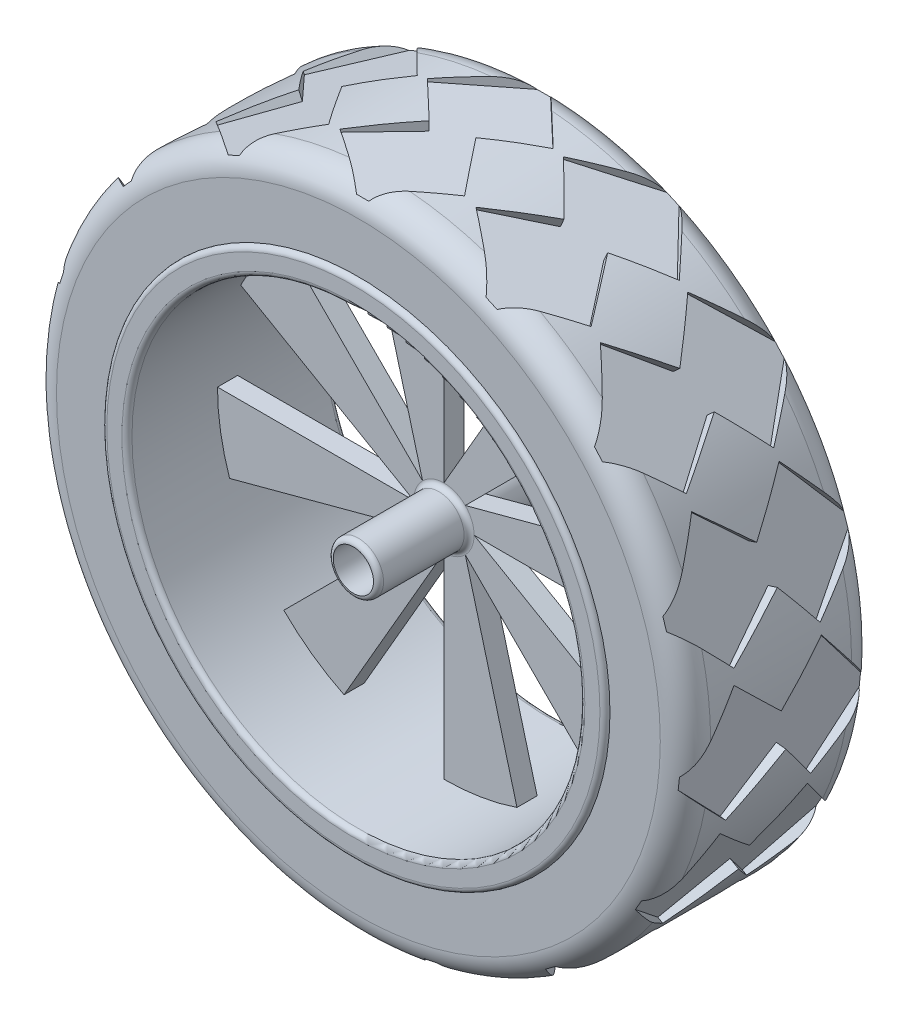
from build123d import *

# Parameters (mm, degrees)
CROQUIS2_R            = 4
CORTAR_EXTRUIR1_DEPTH = 41
CORTAR_EXTRUIR2_DEPTH = 23
CORTAR_EXTRUIR3_DEPTH = 2
MATRIZC1_COUNT        = 15


with BuildPart() as part:
    # Croquis1 → Revolución1 (revolve)
    with BuildSketch(Plane(origin=(0, 0, 0), x_dir=(0, 0, -1), z_dir=(1, 0, 0))):
        with BuildLine():
            Line((0, 0), (-19, 0))
            ThreePointArc((-19, 0), (-19.707107, 0.292893), (-20, 1))
            Line((-20, 1), (-20, 4))
            ThreePointArc((-20, 4), (-19.707107, 4.707107), (-19, 5))
            Line((-19, 5), (-3, 5))
            ThreePointArc((-3, 5), (-2.292893, 5.292893), (-2, 6))
            Line((-2, 6), (-2, 45))
            Line((-2, 45), (-19, 45))
            ThreePointArc((-19, 45), (-19.707107, 45.292893), (-20, 46))
            Line((-20, 46), (-20, 49))
            ThreePointArc((-20, 49), (-19.707107, 49.707107), (-19, 50))
            Line((-19, 50), (19, 50))
            ThreePointArc((19, 50), (19.707107, 49.707107), (20, 49))
            Line((20, 49), (20, 46))
            ThreePointArc((20, 46), (19.707107, 45.292893), (19, 45))
            Line((19, 45), (2, 45))
            Line((2, 45), (2, 6))
            ThreePointArc((2, 6), (2.292893, 5.292893), (3, 5))
            Line((3, 5), (19, 5))
            ThreePointArc((19, 5), (19.707107, 4.707107), (20, 4))
            Line((20, 4), (20, 1))
            ThreePointArc((20, 1), (19.707107, 0.292893), (19, 0))
            Line((19, 0), (0, 0))
        make_face()
    revolve(axis=Axis((0, 0, 0), (0, 0, -1)))

    # Croquis2 → Cortar-Extruir1 (cut, through all)
    with BuildSketch(Plane.XY.offset(20)):
        Circle(CROQUIS2_R)
    extrude(amount=-CORTAR_EXTRUIR1_DEPTH, mode=Mode.SUBTRACT)

    # Croquis3 → Cortar-Extruir2 (cut, through all)
    with BuildSketch(Plane.XY.offset(2)):
        with BuildLine():
            Line((0, 45), (0, 6))
            Line((0, 6), (19.851868, 40.384444))
            ThreePointArc((19.851868, 40.384444), (10.190682, 43.830925), (0, 45))
        make_face()
        with BuildLine():
            Line((31.819805, 31.819805), (4.242641, 4.242641))
            Line((4.242641, 4.242641), (42.593505, 14.518724))
            ThreePointArc((42.593505, 14.518724), (38.199045, 23.787244), (31.819805, 31.819805))
        make_face()
        with BuildLine():
            Line((45, 0), (6, 0))
            Line((6, 0), (40.384444, -19.851868))
            ThreePointArc((40.384444, -19.851868), (43.830925, -10.190682), (45, 0))
        make_face()
        with BuildLine():
            Line((31.819805, -31.819805), (4.242641, -4.242641))
            Line((4.242641, -4.242641), (14.518724, -42.593505))
            ThreePointArc((14.518724, -42.593505), (23.787244, -38.199045), (31.819805, -31.819805))
        make_face()
        with BuildLine():
            Line((0, -45), (0, -6))
            Line((0, -6), (-19.851868, -40.384444))
            ThreePointArc((-19.851868, -40.384444), (-10.190682, -43.830925), (0, -45))
        make_face()
        with BuildLine():
            Line((-31.819805, -31.819805), (-4.242641, -4.242641))
            Line((-4.242641, -4.242641), (-42.593505, -14.518724))
            ThreePointArc((-42.593505, -14.518724), (-38.199045, -23.787244), (-31.819805, -31.819805))
        make_face()
        with BuildLine():
            Line((-45, 0), (-6, 0))
            Line((-6, 0), (-40.384444, 19.851868))
            ThreePointArc((-40.384444, 19.851868), (-43.830925, 10.190682), (-45, 0))
        make_face()
        with BuildLine():
            Line((-31.819805, 31.819805), (-4.242641, 4.242641))
            Line((-4.242641, 4.242641), (-14.518724, 42.593505))
            ThreePointArc((-14.518724, 42.593505), (-23.787244, 38.199045), (-31.819805, 31.819805))
        make_face()
    extrude(amount=-CORTAR_EXTRUIR2_DEPTH, mode=Mode.SUBTRACT)

    # Croquis4 → Revolución2 (revolve)
    with BuildSketch(Plane(origin=(0, 0, 0), x_dir=(0, 0, -1), z_dir=(1, 0, 0))):
        with BuildLine():
            Line((-19, 50), (19, 50))
            Line((19, 50), (19, 60))
            ThreePointArc((19, 60), (17.535534, 63.535534), (14, 65))
            Line((14, 65), (-14, 65))
            ThreePointArc((-14, 65), (-17.535534, 63.535534), (-19, 60))
            Line((-19, 60), (-19, 50))
        make_face()
    revolve(axis=Axis((0, 0, -20), (0, 0, 1)))

    # Croquis5 → Cortar-Extruir3 (cut)
    with BuildSketch(Plane(origin=(0, 65, 0), x_dir=(1, 0, 0), z_dir=(0, 1, 0))):
        Polygon((0, -19), (-13.679932, -8.984437), (-5.001829, 0.066308), (-13.679932, 8.387111), (0, 19.132615), (11.328917, 8.387111), (2.703164, 1.653485), (10.75651, -8.662826), align=None)
    cortar_extruir3 = extrude(amount=-CORTAR_EXTRUIR3_DEPTH, mode=Mode.SUBTRACT)

    # MatrizC1: Cortar-Extruir3 ×15 about axis
    matrizc1_axis = Axis((0, 0, 0), (0, 0, 1))
    for i in range(1, MATRIZC1_COUNT):
        add(cortar_extruir3.rotate(matrizc1_axis, i * 360 / MATRIZC1_COUNT), mode=Mode.SUBTRACT)


solid = part.part
